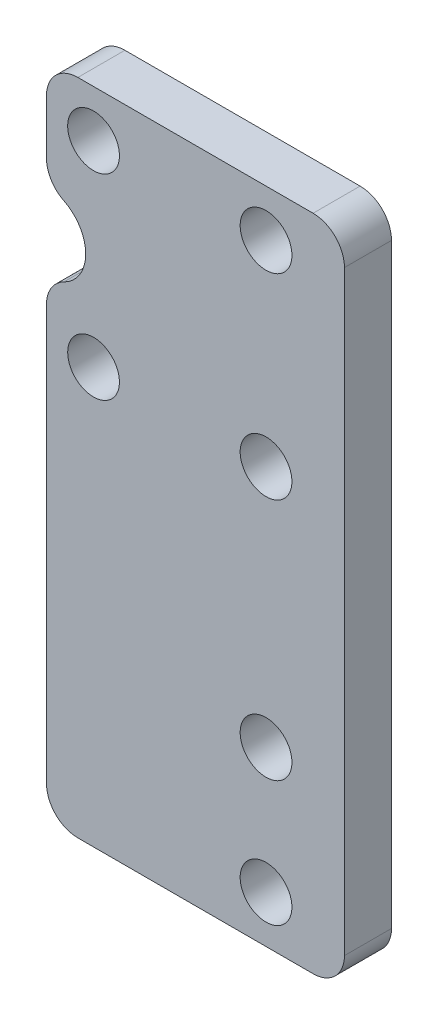
from build123d import *

# Parameters (mm, degrees)
SKETCH_1_W          = 19
SKETCH_1_H          = 42
SKETCH_1_R          = 1.65
EXTRUDE_1_DEPTH     = 3
SKETCH_2_R          = 2.5
CUT_EXTRUDE_1_DEPTH = 4
FILLET_1_R          = 2
FILLET_2_R          = 2


with BuildPart() as part:
    # 草图1 → 凸台-拉伸1 (new body)
    with BuildSketch(Plane.XY):
        Rectangle(SKETCH_1_W, SKETCH_1_H)
        with Locations((-6.5, 18)):
            Circle(SKETCH_1_R, mode=Mode.SUBTRACT)
        with Locations((-6.5, 5.5)):
            Circle(SKETCH_1_R, mode=Mode.SUBTRACT)
        with Locations((4.5, -10)):
            Circle(SKETCH_1_R, mode=Mode.SUBTRACT)
        with Locations((4.5, -18)):
            Circle(SKETCH_1_R, mode=Mode.SUBTRACT)
        with Locations((4.5, 18)):
            Circle(SKETCH_1_R, mode=Mode.SUBTRACT)
        with Locations((4.5, 5.5)):
            Circle(SKETCH_1_R, mode=Mode.SUBTRACT)
    extrude(amount=EXTRUDE_1_DEPTH)

    # 草图2 → 切除-拉伸1 (cut, through all)
    with BuildSketch(Plane.XY.offset(3)):
        with Locations((-9.5, 11.5)):
            Circle(SKETCH_2_R)
    extrude(amount=-CUT_EXTRUDE_1_DEPTH, mode=Mode.SUBTRACT)

    # 圆角1
    fillet_1_edges = [part.edges().sort_by_distance(p)[0] for p in [
        (-9.5, 9, 1.5),
        (-9.5, 14, 1.5),
    ]]
    fillet(fillet_1_edges, radius=FILLET_1_R)

    # 圆角2
    fillet_2_edges = [part.edges().sort_by_distance(p)[0] for p in [
        (9.5, -21, 1.5),
        (-9.5, -21, 1.5),
        (-9.5, 21, 1.5),
        (9.5, 21, 1.5),
    ]]
    fillet(fillet_2_edges, radius=FILLET_2_R)


solid = part.part
